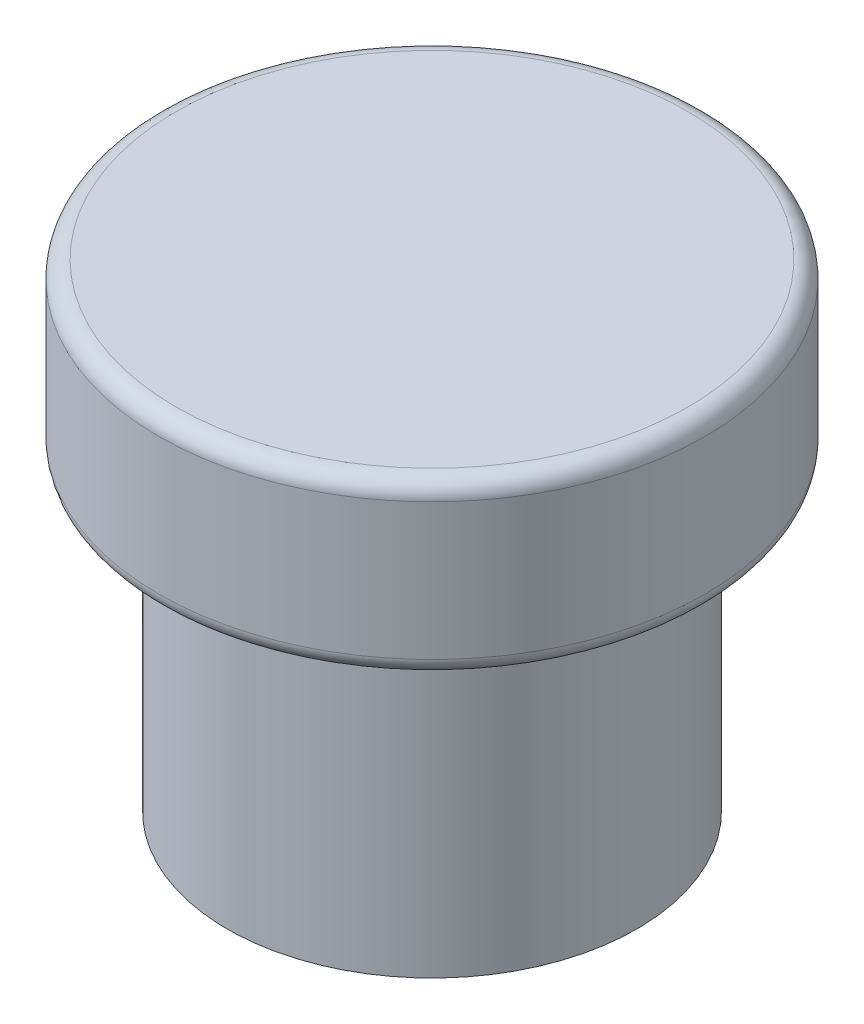
from build123d import *

# Parameters (mm, degrees)
FILLET1_R          = 0.5
SKETCH2_R          = 5.7
CUT_EXTRUDE1_DEPTH = 10


with BuildPart() as part:
    # Sketch1 → Revolve1 (revolve)
    with BuildSketch(Plane(origin=(0, 0, 0), x_dir=(0, 0, -1), z_dir=(1, 0, 0))):
        Polygon((6, 9), (8, 9), (8, 14), (0, 14), (0, 9), (0, 0), (6, 0), align=None)
    revolve(axis=Axis((0, 0, 0), (0, 1, 0)))

    # Fillet1
    fillet1_edges = [part.edges().sort_by_distance(p)[0] for p in [
        (0, 9, 8),
        (0, 14, 8),
    ]]
    fillet(fillet1_edges, radius=FILLET1_R)

    # Sketch2 → Cut-Extrude1 (cut)
    with BuildSketch(Plane.XZ):
        Circle(SKETCH2_R)
    extrude(amount=-CUT_EXTRUDE1_DEPTH, mode=Mode.SUBTRACT)


solid = part.part
